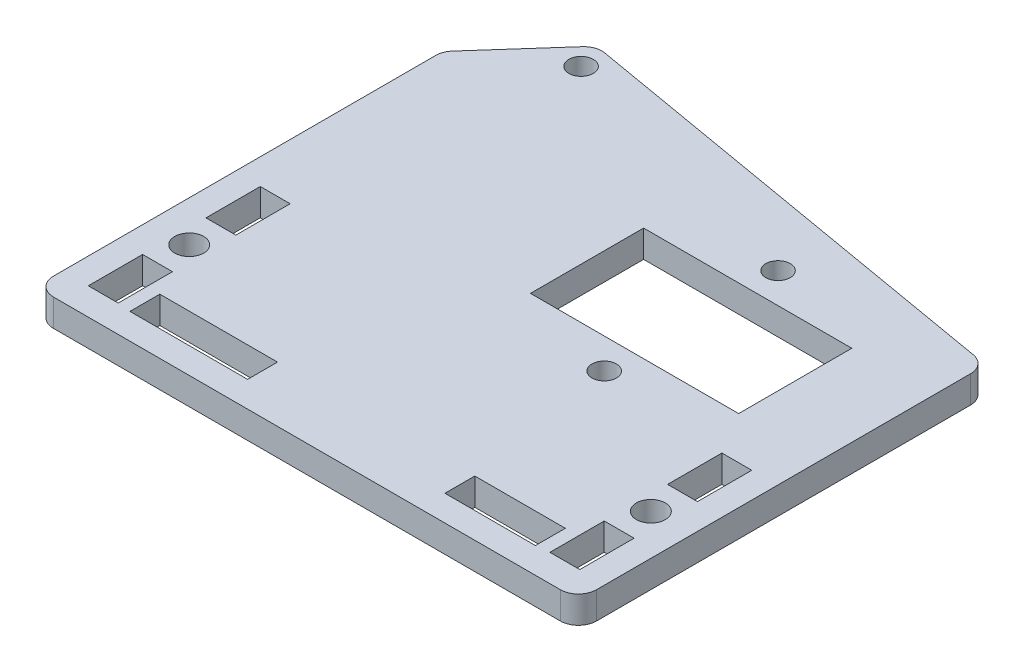
from build123d import *

# Parameters (mm, degrees)
BOSS_EXTRUDE1_DEPTH = 3
SKETCH2_R           = 1.35
SKETCH2_R_2         = 1.6
SKETCH2_W           = 3
SKETCH2_H           = 6
SKETCH2_W_2         = 13
SKETCH2_H_2         = 3
SKETCH2_W_3         = 10
SKETCH2_W_4         = 23
SKETCH2_H_3         = 12.5
MAIN_HOLES_DEPTH    = 4
SKETCH3_W           = 0.15
SKETCH3_H           = 6
SKETCH3_W_2         = 10
SKETCH3_H_2         = 0.15
SKETCH3_W_3         = 13
TOLERANCE_DEPTH     = 4


with BuildPart() as part:
    # Sketch1 → Boss-Extrude1 (new body)
    with BuildSketch(Plane(origin=(0, 0, 0), x_dir=(1, 0, 0), z_dir=(0, 1, 0))):
        with BuildLine():
            Line((58.341082867, 45.287120273), (9.096557402, 53.810211219))
            ThreePointArc((9.096557402, 53.810211219), (8.095316223, 53.72741672), (7.260655898, 53.168237885))
            Line((7.260655898, 53.168237885), (0.505181363, 45.568329033))
            ThreePointArc((0.505181363, 45.568329033), (0.130556597, 44.95036247), (0, 44.239601355))
            Line((0, 44.239601355), (0, 2))
            ThreePointArc((0, 2), (0.585786438, 0.585786438), (2, 0))
            Line((2, 0), (58, 0))
            ThreePointArc((58, 0), (59.414213562, 0.585786438), (60, 2))
            Line((60, 2), (60, 43.316419261))
            ThreePointArc((60, 43.316419261), (59.530059759, 44.604408831), (58.341082867, 45.287120273))
        make_face()
    extrude(amount=BOSS_EXTRUDE1_DEPTH)

    # Sketch2 → Main Holes (cut, through all)
    with BuildSketch(Plane(origin=(0, 3, 0), x_dir=(1, 0, 0), z_dir=(0, 1, 0))):
        with Locations((9.079882179, 51.212916529)):
            Circle(SKETCH2_R)
        with Locations((39.5, 42.55)):
            Circle(SKETCH2_R)
        with Locations((39.5, 23.35)):
            Circle(SKETCH2_R)
        with Locations((55.5, 12.5)):
            Circle(SKETCH2_R_2)
        with Locations((4.5, 12.5)):
            Circle(SKETCH2_R_2)
        with Locations((4.5, 6)):
            Rectangle(SKETCH2_W, SKETCH2_H)
        with Locations((4.5, 19)):
            Rectangle(SKETCH2_W, SKETCH2_H)
        with Locations((55.5, 6)):
            Rectangle(SKETCH2_W, SKETCH2_H)
        with Locations((55.5, 19)):
            Rectangle(SKETCH2_W, SKETCH2_H)
        with Locations((14.1, 4.5)):
            Rectangle(SKETCH2_W_2, SKETCH2_H_2)
        with Locations((47.4, 4.5)):
            Rectangle(SKETCH2_W_3, SKETCH2_H_2)
        with Locations((39.5, 32.95)):
            Rectangle(SKETCH2_W_4, SKETCH2_H_3)
    extrude(amount=-MAIN_HOLES_DEPTH, mode=Mode.SUBTRACT)

    # Sketch3 → Tolerance (cut, through all)
    with BuildSketch(Plane(origin=(0, 3, 0), x_dir=(1, 0, 0), z_dir=(0, 1, 0))):
        with Locations((6.075, 19)):
            Rectangle(SKETCH3_W, SKETCH3_H)
        with Locations((2.925, 19)):
            Rectangle(SKETCH3_W, SKETCH3_H)
        with Locations((6.075, 6)):
            Rectangle(SKETCH3_W, SKETCH3_H)
        with Locations((2.925, 6)):
            Rectangle(SKETCH3_W, SKETCH3_H)
        with Locations((57.075, 6)):
            Rectangle(SKETCH3_W, SKETCH3_H)
        with Locations((53.925, 6)):
            Rectangle(SKETCH3_W, SKETCH3_H)
        with Locations((57.075, 19)):
            Rectangle(SKETCH3_W, SKETCH3_H)
        with Locations((53.925, 19)):
            Rectangle(SKETCH3_W, SKETCH3_H)
        with Locations((47.4, 6.075)):
            Rectangle(SKETCH3_W_2, SKETCH3_H_2)
        with Locations((47.4, 2.925)):
            Rectangle(SKETCH3_W_2, SKETCH3_H_2)
        with Locations((14.1, 6.075)):
            Rectangle(SKETCH3_W_3, SKETCH3_H_2)
        with Locations((14.1, 2.925)):
            Rectangle(SKETCH3_W_3, SKETCH3_H_2)
    extrude(amount=-TOLERANCE_DEPTH, mode=Mode.SUBTRACT)


solid = part.part
